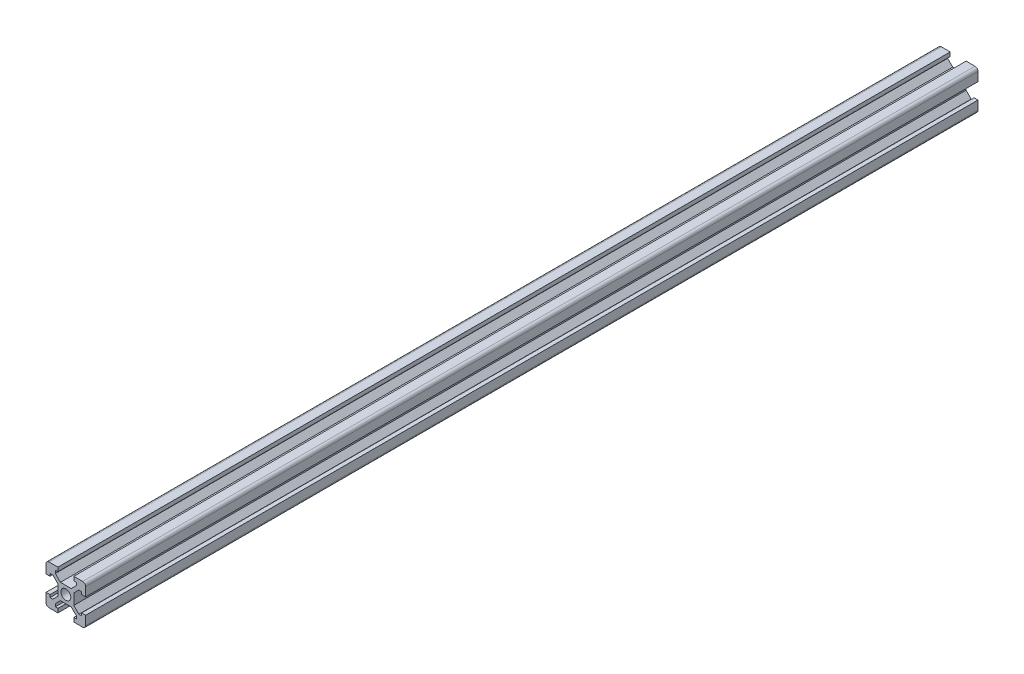
from build123d import *

# Parameters (mm, degrees)
SKETCH_1_R      = 2.5
EXTRUDE_1_DEPTH = 450
FILLET_1_R      = 1.5


with BuildPart() as part:
    # Эскиз1 → Бобышка-Вытянуть1 (new body)
    with BuildSketch(Plane.XY):
        Polygon((14, 20), (20, 20), (20, 14), (18, 14), (18, 15.3), (16.572792206, 15.3), (14, 12.727207794), (14, 7.272792206), (16.572792206, 4.7), (18, 4.7), (18, 6), (20, 6), (20, 0), (14, 0), (14, 2), (15.3, 2), (15.3, 3.427207794), (12.684044775, 6), (7.272792206, 6), (4.7, 3.427207794), (4.7, 2), (6, 2), (6, 0), (0, 0), (0, 6), (2, 6), (2, 4.7), (3.427207794, 4.7), (6, 7.272792206), (6, 12.727207794), (3.427207794, 15.3), (2, 15.3), (2, 14), (0, 14), (0, 20), (6, 20), (6, 18), (4.7, 18), (4.7, 16.572792206), (7.272792206, 14), (12.727207794, 14), (15.3, 16.572792206), (15.3, 18), (14, 18), align=None)
        with Locations((10, 10)):
            Circle(SKETCH_1_R, mode=Mode.SUBTRACT)
    extrude(amount=EXTRUDE_1_DEPTH)

    # Скругление1
    fillet_1_edges = [part.edges().sort_by_distance(p)[0] for p in [
        (0, 20, 225),
        (20, 20, 225),
        (20, 0, 225),
        (0, 0, 225),
    ]]
    fillet(fillet_1_edges, radius=FILLET_1_R)


solid = part.part
